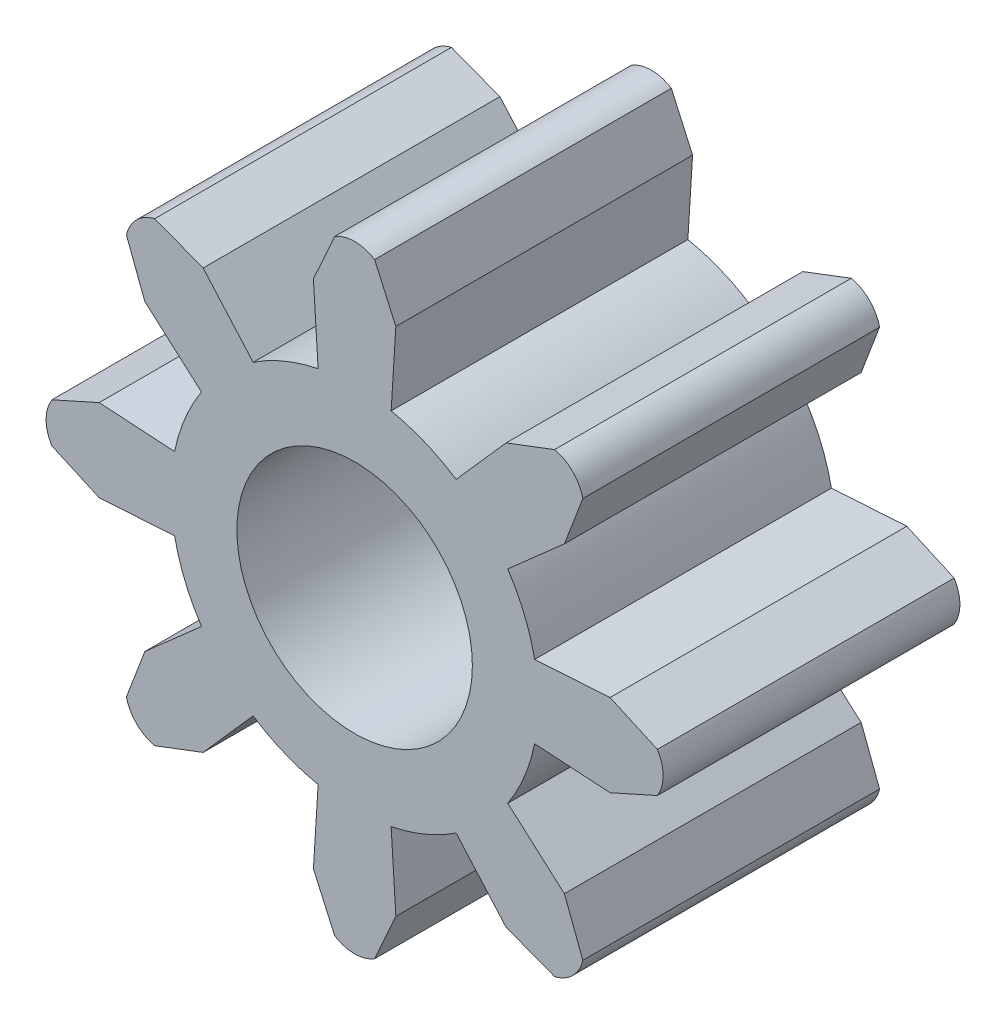
from build123d import *

# Parameters (mm, degrees)
SZKIC1_R                    = 2.5
DODANIE_WYCI_GNI_CIE1_DEPTH = 6.3


with BuildPart() as part:
    # Szkic1 → Dodanie-wyciągnięcie1 (new body)
    with BuildSketch(Plane.XY):
        with BuildLine():
            Line((0.875, 5.423398291), (0.775, 3.822221213))
            ThreePointArc((0.775, 3.822221213), (1.492465386, 3.603130177), (2.154710783, 3.250726294))
            Line((2.154710783, 3.250726294), (3.216203275, 4.453640142))
            Line((3.216203275, 4.453640142), (4.245186445, 4.844987722))
            ThreePointArc((4.245186445, 4.844987722), (4.453444634, 4.765560203), (4.631549417, 4.631549417))
            ThreePointArc((4.631549417, 4.631549417), (4.765560203, 4.453444634), (4.844987722, 4.245186445))
            Line((4.844987722, 4.245186445), (4.453640142, 3.216203275))
            Line((4.453640142, 3.216203275), (3.250726294, 2.154710783))
            ThreePointArc((3.250726294, 2.154710783), (3.603130177, 1.492465386), (3.822221213, 0.775))
            Line((3.822221213, 0.775), (5.423398291, 0.875))
            Line((5.423398291, 0.875), (6.427723795, 0.424123551))
            ThreePointArc((6.427723795, 0.424123551), (6.518820836, 0.220699035), (6.55, 0))
            ThreePointArc((6.55, 0), (6.518820836, -0.220699035), (6.427723795, -0.424123551))
            Line((6.427723795, -0.424123551), (5.423398291, -0.875))
            Line((5.423398291, -0.875), (3.822221213, -0.775))
            ThreePointArc((3.822221213, -0.775), (3.603130177, -1.492465386), (3.250726294, -2.154710783))
            Line((3.250726294, -2.154710783), (4.453640142, -3.216203275))
            Line((4.453640142, -3.216203275), (4.844987722, -4.245186445))
            ThreePointArc((4.844987722, -4.245186445), (4.765560203, -4.453444634), (4.631549417, -4.631549417))
            ThreePointArc((4.631549417, -4.631549417), (4.453444634, -4.765560203), (4.245186445, -4.844987722))
            Line((4.245186445, -4.844987722), (3.216203275, -4.453640142))
            Line((3.216203275, -4.453640142), (2.154710783, -3.250726294))
            ThreePointArc((2.154710783, -3.250726294), (1.492465386, -3.603130177), (0.775, -3.822221213))
            Line((0.775, -3.822221213), (0.875, -5.423398291))
            Line((0.875, -5.423398291), (0.424123551, -6.427723795))
            ThreePointArc((0.424123551, -6.427723795), (0.220699035, -6.518820836), (0, -6.55))
            ThreePointArc((0, -6.55), (-0.220699035, -6.518820836), (-0.424123551, -6.427723795))
            Line((-0.424123551, -6.427723795), (-0.875, -5.423398291))
            Line((-0.875, -5.423398291), (-0.775, -3.822221213))
            ThreePointArc((-0.775, -3.822221213), (-1.492465386, -3.603130177), (-2.154710783, -3.250726294))
            Line((-2.154710783, -3.250726294), (-3.216203275, -4.453640142))
            Line((-3.216203275, -4.453640142), (-4.245186445, -4.844987722))
            ThreePointArc((-4.245186445, -4.844987722), (-4.453444634, -4.765560203), (-4.631549417, -4.631549417))
            ThreePointArc((-4.631549417, -4.631549417), (-4.765560203, -4.453444634), (-4.844987722, -4.245186445))
            Line((-4.844987722, -4.245186445), (-4.453640142, -3.216203275))
            Line((-4.453640142, -3.216203275), (-3.250726294, -2.154710783))
            ThreePointArc((-3.250726294, -2.154710783), (-3.603130177, -1.492465386), (-3.822221213, -0.775))
            Line((-3.822221213, -0.775), (-5.423398291, -0.875))
            Line((-5.423398291, -0.875), (-6.427723795, -0.424123551))
            ThreePointArc((-6.427723795, -0.424123551), (-6.518820836, -0.220699035), (-6.55, 0))
            ThreePointArc((-6.55, 0), (-6.518820836, 0.220699035), (-6.427723795, 0.424123551))
            Line((-6.427723795, 0.424123551), (-5.423398291, 0.875))
            Line((-5.423398291, 0.875), (-3.822221213, 0.775))
            ThreePointArc((-3.822221213, 0.775), (-3.603130177, 1.492465386), (-3.250726294, 2.154710783))
            Line((-3.250726294, 2.154710783), (-4.453640142, 3.216203275))
            Line((-4.453640142, 3.216203275), (-4.844987722, 4.245186445))
            ThreePointArc((-4.844987722, 4.245186445), (-4.765560203, 4.453444634), (-4.631549417, 4.631549417))
            ThreePointArc((-4.631549417, 4.631549417), (-4.453444634, 4.765560203), (-4.245186445, 4.844987722))
            Line((-4.245186445, 4.844987722), (-3.216203275, 4.453640142))
            Line((-3.216203275, 4.453640142), (-2.154710783, 3.250726294))
            ThreePointArc((-2.154710783, 3.250726294), (-1.492465386, 3.603130177), (-0.775, 3.822221213))
            Line((-0.775, 3.822221213), (-0.875, 5.423398291))
            Line((-0.875, 5.423398291), (-0.424123551, 6.427723795))
            ThreePointArc((-0.424123551, 6.427723795), (-0.220699035, 6.518820836), (0, 6.55))
            ThreePointArc((0, 6.55), (0.220699035, 6.518820836), (0.424123551, 6.427723795))
            Line((0.424123551, 6.427723795), (0.875, 5.423398291))
        make_face()
        Circle(SZKIC1_R, mode=Mode.SUBTRACT)
    extrude(amount=DODANIE_WYCI_GNI_CIE1_DEPTH)


solid = part.part
